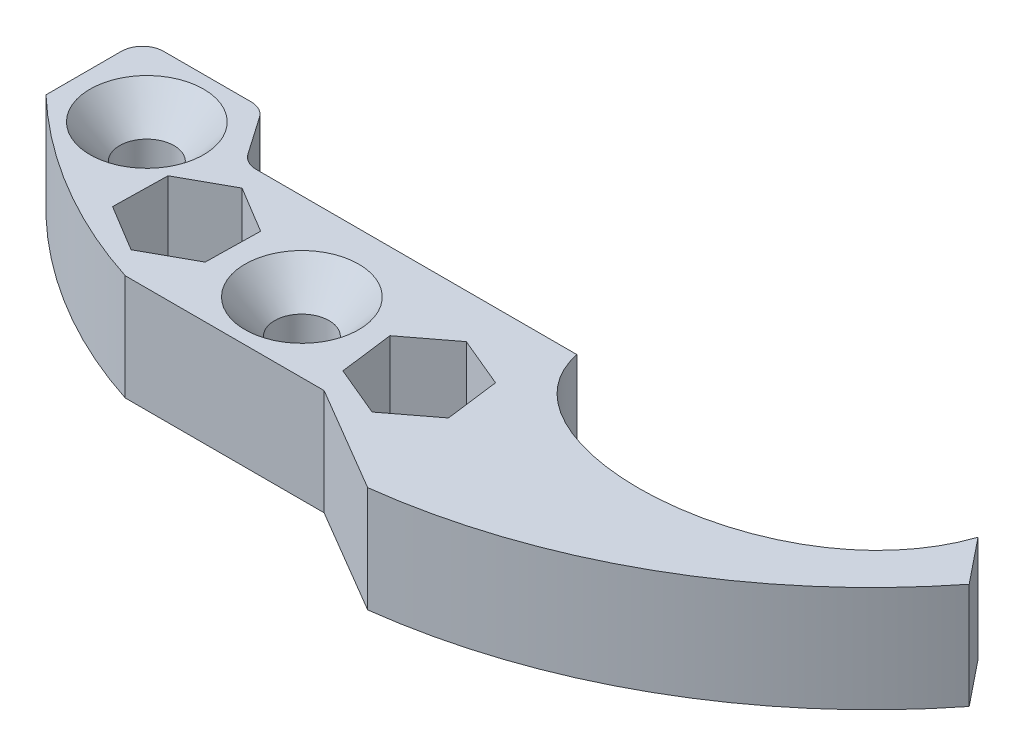
from build123d import *

# Parameters (mm, degrees)
SKETCH1_R             = 3.2639
BOSS_EXTRUDE1_DEPTH   = 12.7
CHAMFER1_SIZE         = 4.0894
CHAMFER1_SIZE2        = 3.554861186
CHAMFER1_PART_2_SIZE  = 4.0894
CHAMFER1_PART_2_SIZE2 = 3.554861186
CUT_EXTRUDE1_DEPTH    = 13.7000001


with BuildPart() as part:
    # Sketch1 → Boss-Extrude1 (new body)
    with BuildSketch(Plane(origin=(0, 0, 0), x_dir=(1, 0, 0), z_dir=(0, 1, 0))):
        with BuildLine():
            Line((-8.873253367, 0), (29.595519551, 0))
            add(Edge.make_bspline(
                [(29.595519551, 0), (32.608022391, -14.845023466), (66.17675893, -13.698872415), (72.627485997, 5.074574194)],
                knots=[0, 0, 0, 0, 1, 1, 1, 1], degree=3))
            Line((72.627485997, 5.074574194), (76.972410672, -0.328799158))
            ThreePointArc((76.972410672, -0.328799158), (56.487992256, -17.897771795), (30.865519551, -26.369435729))
            Line((30.865519551, -26.369435729), (18.165519551, -18.896027316))
            Line((18.165519551, -18.896027316), (-5.688817186, -18.896027316))
            ThreePointArc((-5.688817186, -18.896027316), (-18.253794481, -13.20459823), (-29.23375861, -4.855262498))
            Line((-29.23375861, -4.855262498), (-29.23375861, 4.177286104))
            ThreePointArc((-29.23375861, 4.177286104), (-28.489809834, 5.973337328), (-26.69375861, 6.717286104))
            Line((-26.69375861, 6.717286104), (-16.191261416, 6.717286104))
            ThreePointArc((-16.191261416, 6.717286104), (-15.013419953, 6.427683732), (-14.10416564, 5.624915621))
            Line((-14.10416564, 5.624915621), (-10.960349143, 1.092370482))
            ThreePointArc((-10.960349143, 1.092370482), (-10.05109483, 0.289602371), (-8.873253367, 0))
        make_face()
        with Locations((-20.368787798, -1.624222444)):
            Circle(SKETCH1_R, mode=Mode.SUBTRACT)
        with Locations((-7.908365266, -9.317144856)):
            Circle(SKETCH1_R, mode=Mode.SUBTRACT)
        with Locations((7.107001098, -10.503835127)):
            Circle(SKETCH1_R, mode=Mode.SUBTRACT)
        with Locations((22.444824189, -11.767482364)):
            Circle(SKETCH1_R, mode=Mode.SUBTRACT)
    extrude(amount=BOSS_EXTRUDE1_DEPTH)

    # Chamfer1
    chamfer1_edges = [part.edges().sort_by_distance(p)[0] for p in [
        (-23.632687798, 12.7, 1.624222444),
    ]]
    chamfer1_side = [part.faces().sort_by_distance(p)[0] for p in [
        (-23.632687798, 6.35, 1.624222444),
    ]]
    chamfer(chamfer1_edges, length=CHAMFER1_SIZE, length2=CHAMFER1_SIZE2, reference=chamfer1_side[0])

    # Chamfer1 part 2
    chamfer1_part_2_edges = [part.edges().sort_by_distance(p)[0] for p in [
        (3.843101098, 12.7, 10.503835127),
    ]]
    chamfer1_part_2_side = [part.faces().sort_by_distance(p)[0] for p in [
        (3.843101098, 6.35, 10.503835127),
    ]]
    chamfer(chamfer1_part_2_edges, length=CHAMFER1_PART_2_SIZE, length2=CHAMFER1_PART_2_SIZE2, reference=chamfer1_part_2_side[0])

    # Sketch2 → Cut-Extrude1 (cut, through all)
    with BuildSketch(Plane(origin=(0, 12.7, 0), x_dir=(1, 0, 0), z_dir=(0, 1, 0))):
        Polygon((-2.191584648, -6.154850089), (-7.78860256, -2.78512023), (-13.505383178, -5.947414997), (-13.625145885, -12.479439623), (-8.028127973, -15.849169483), (-2.311347355, -12.686874716), align=None)
        Polygon((28.471794253, -14.28885514), (27.641882098, -7.808659569), (21.614912034, -5.287286792), (16.417854125, -9.246109587), (17.247766281, -15.726305159), (23.274736345, -18.247677935), align=None)
    extrude(amount=-CUT_EXTRUDE1_DEPTH, mode=Mode.SUBTRACT)


solid = part.part
